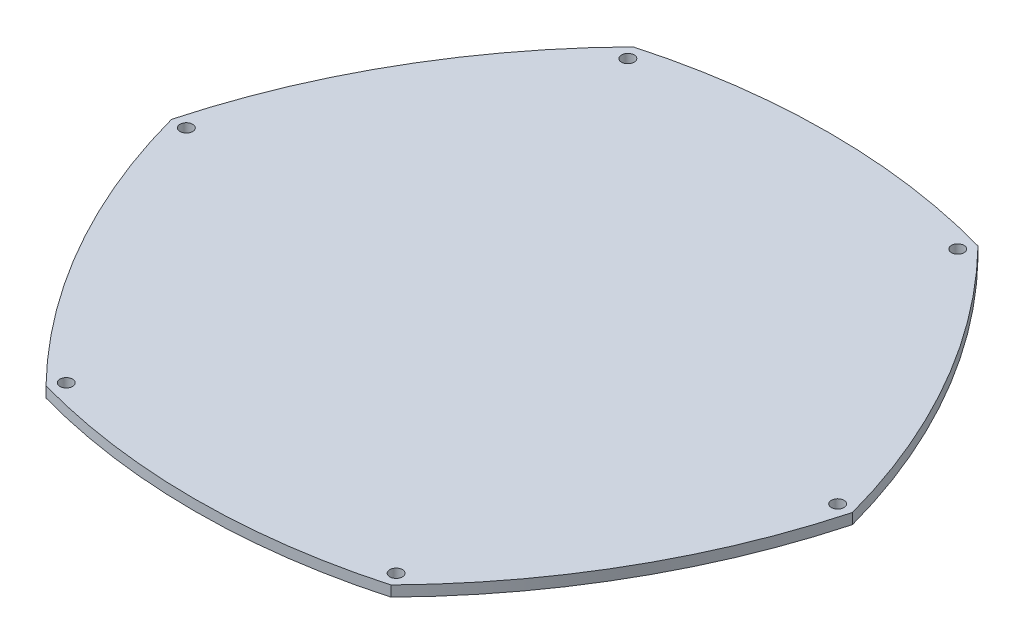
from build123d import *

# Parameters (mm, degrees)
SKETCH1_R           = 75
SKETCH1_R_2         = 73.5
SKETCH1_R_3         = 1.5
BOSS_EXTRUDE1_DEPTH = 2.5


with BuildPart() as part:
    # Sketch1 → Boss-Extrude1 (new body)
    with BuildSketch(Plane(origin=(0, 0, 0), x_dir=(1, 0, 0), z_dir=(0, 1, 0))):
        Circle(SKETCH1_R)
        Circle(SKETCH1_R_2, mode=Mode.SUBTRACT)
        Circle(SKETCH1_R_2)
        with BuildLine():
            ThreePointArc((-65.092339325, -37.255702398), (-75, -1.885e-06), (-65.092341198, 37.255699125))
            ThreePointArc((-65.092341198, 37.255699125), (-73.987141009, 19.120393419), (-80.5, 0))
            ThreePointArc((-80.5, 0), (-73.987140288, -19.120395161), (-65.092339325, -37.255702398))
        make_face()
        with Locations(Location((-77, 0, 0), (0, 0, 270))):
            Circle(SKETCH1_R_3, mode=Mode.SUBTRACT)
        with BuildLine():
            ThreePointArc((-40.772727273, -69.410623904), (-20.577028262, -73.596152049), (5.64e-07, -75))
            ThreePointArc((5.64e-07, -75), (-37.621950265, -64.881344455), (-65.092339325, -37.255702398))
            ThreePointArc((-65.092339325, -37.255702398), (-53.960444579, -54.110599462), (-40.772727273, -69.410623904))
        make_face()
        with Locations(Location((-39, -66.392770691, 0), (0, 0, 270))):
            Circle(SKETCH1_R_3, mode=Mode.SUBTRACT)
        with BuildLine():
            ThreePointArc((40.772727273, -69.410623904), (53.960444658, -54.110599358), (65.092339455, -37.255702172))
            ThreePointArc((65.092339455, -37.255702172), (37.621950865, -64.881344107), (5.64e-07, -75))
            ThreePointArc((5.64e-07, -75), (20.577028821, -73.596151973), (40.772727273, -69.410623904))
        make_face()
        with Locations(Location((39, -66.392770691, 0), (0, 0, 270))):
            Circle(SKETCH1_R_3, mode=Mode.SUBTRACT)
        with BuildLine():
            ThreePointArc((65.092339583, 37.255701948), (72.480774929, 19.27530196), (75, 0))
            ThreePointArc((75, 0), (72.480774896, -19.275302084), (65.092339455, -37.255702172))
            ThreePointArc((65.092339455, -37.255702172), (73.987140338, -19.120395041), (80.5, 0))
            ThreePointArc((80.5, 0), (73.987140387, 19.120394921), (65.092339583, 37.255701948))
        make_face()
        with Locations(Location((77, 0, 0), (0, 0, 270))):
            Circle(SKETCH1_R_3, mode=Mode.SUBTRACT)
        with BuildLine():
            ThreePointArc((-4.58e-07, 75), (37.621950535, 64.881344298), (65.092339583, 37.255701948))
            ThreePointArc((65.092339583, 37.255701948), (53.960444736, 54.110599255), (40.772727273, 69.410623904))
            ThreePointArc((40.772727273, 69.410623904), (20.577028315, 73.596152042), (-4.58e-07, 75))
        make_face()
        with Locations(Location((39, 66.392770691, 0), (0, 0, 270))):
            Circle(SKETCH1_R_3, mode=Mode.SUBTRACT)
        with BuildLine():
            ThreePointArc((-65.092341198, 37.255699125), (-37.621952338, 64.881343253), (-4.58e-07, 75))
            ThreePointArc((-4.58e-07, 75), (-20.577028768, 73.59615198), (-40.772727273, 69.410623904))
            ThreePointArc((-40.772727273, 69.410623904), (-53.960445716, 54.110597958), (-65.092341198, 37.255699125))
        make_face()
        with Locations(Location((-39, 66.392770691, 0), (0, 0, 270))):
            Circle(SKETCH1_R_3, mode=Mode.SUBTRACT)
    extrude(amount=BOSS_EXTRUDE1_DEPTH)


solid = part.part
